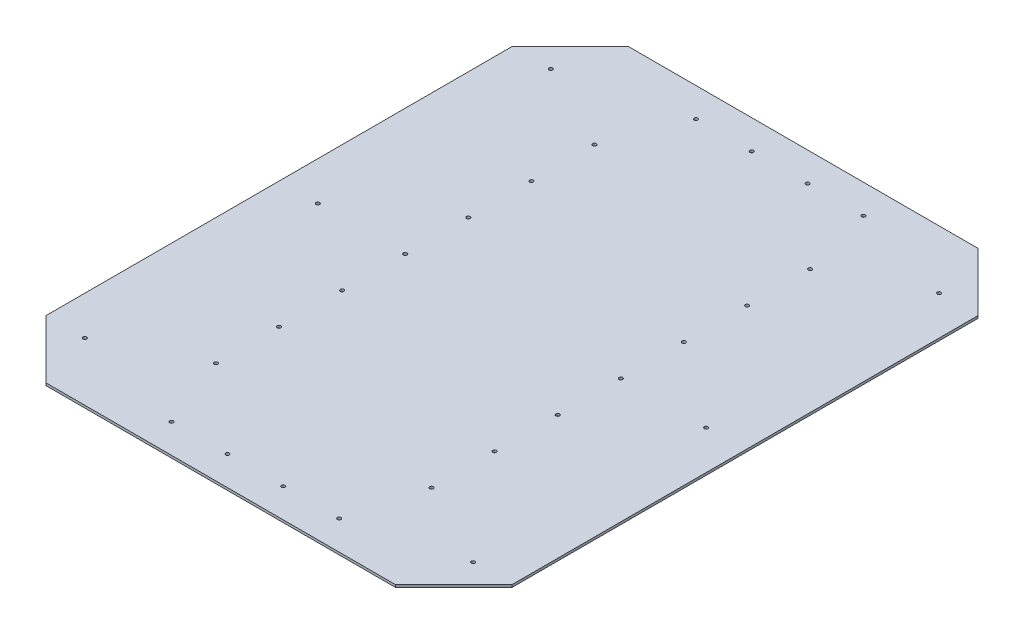
from build123d import *

# Parameters (mm, degrees)
SKETCH1_W               = 1219.2
SKETCH1_H               = 1524
BOSS_EXTRUDE1_DEPTH     = 6.35
SKETCH20_R              = 1360.3436129
SKETCH20_R_2            = 1357.8036129
CUT_EXTRUDE_THIN2_DEPTH = 6.35
SKETCH24_R              = 4.7625
CUT_EXTRUDE13_DEPTH     = 976.856794053


with BuildPart() as part:
    # Sketch1 → Boss-Extrude1 (new body)
    with BuildSketch(Plane(origin=(0, 0, 0), x_dir=(1, 0, 0), z_dir=(0, 1, 0))):
        Rectangle(SKETCH1_W, SKETCH1_H)
    extrude(amount=BOSS_EXTRUDE1_DEPTH)

    # Sketch20 → Cut-Extrude-Thin2 (cut)
    with BuildSketch(Plane(origin=(0, 6.35, 0), x_dir=(1, 0, 0), z_dir=(0, 1, 0))):
        Circle(SKETCH20_R)
        Circle(SKETCH20_R_2, mode=Mode.SUBTRACT)
        Polygon((612.14, -610.652102448), (458.252102448, -764.54), (0, -764.54), (-458.252102448, -764.54), (-612.14, -610.652102448), (-612.14, 610.652102448), (-458.252102448, 764.54), (0, 764.54), (458.252102448, 764.54), (612.14, 610.652102448), align=None)
        Polygon((609.6, -609.6), (457.2, -762), (0, -762), (-457.2, -762), (-609.6, -609.6), (-609.6, 609.6), (-457.2, 762), (0, 762), (457.2, 762), (609.6, 609.6), align=None, mode=Mode.SUBTRACT)
    extrude(amount=-CUT_EXTRUDE_THIN2_DEPTH, mode=Mode.SUBTRACT)


with BuildPart() as cut_extrude_thin2_kept_piece:
    # of the separate pieces the step leaves, the one the design keeps (cut_extrude_thin2_pieces_kept)
    add(part.part.solids().sort_by_distance((457.2, 6.35, -762))[0])

    # Sketch24 → Cut-Extrude13 (cut, through all)
    with BuildSketch(Plane.XZ):
        with Locations(Location((-279.400040578, -0.001758284, 0), (0, 0, 270))):
            Circle(SKETCH24_R)
        with Locations(Location((-279.400040578, 165.098241716, 0), (0, 0, 270))):
            Circle(SKETCH24_R)
        with Locations(Location((-279.400040578, 330.198241716, 0), (0, 0, 270))):
            Circle(SKETCH24_R)
        with Locations(Location((-279.400040578, 495.298241716, 0), (0, 0, 270))):
            Circle(SKETCH24_R)
        with Locations(Location((87.436757408, 685.8, 0), (0, 0, 270))):
            Circle(SKETCH24_R)
        with Locations(Location((233.486757408, 685.8, 0), (0, 0, 270))):
            Circle(SKETCH24_R)
        with Locations(Location((284.709719006, 495.298241716, 0), (0, 0, 270))):
            Circle(SKETCH24_R)
        with Locations(Location((284.709719006, 330.198241716, 0), (0, 0, 270))):
            Circle(SKETCH24_R)
        with Locations(Location((284.709719006, 165.098241716, 0), (0, 0, 270))):
            Circle(SKETCH24_R)
        with Locations(Location((284.709719006, -0.001758284, 0), (0, 0, 270))):
            Circle(SKETCH24_R)
        with Locations(Location((284.709719006, -165.101758284, 0), (0, 0, 270))):
            Circle(SKETCH24_R)
        with Locations(Location((284.709719006, -330.201758284, 0), (0, 0, 270))):
            Circle(SKETCH24_R)
        with Locations(Location((284.709719006, -495.301758284, 0), (0, 0, 270))):
            Circle(SKETCH24_R)
        with Locations(Location((233.486757408, -685.8, 0), (0, 0, 270))):
            Circle(SKETCH24_R)
        with Locations(Location((87.436757408, -685.8, 0), (0, 0, 270))):
            Circle(SKETCH24_R)
        with Locations(Location((-58.613242592, -685.8, 0), (0, 0, 270))):
            Circle(SKETCH24_R)
        with Locations(Location((-204.663242592, -685.8, 0), (0, 0, 270))):
            Circle(SKETCH24_R)
        with Locations(Location((-279.400040578, -495.301758284, 0), (0, 0, 270))):
            Circle(SKETCH24_R)
        with Locations(Location((-279.400040578, -330.201758284, 0), (0, 0, 270))):
            Circle(SKETCH24_R)
        with Locations(Location((-279.400040578, -165.101758284, 0), (0, 0, 270))):
            Circle(SKETCH24_R)
        with Locations(Location((508, -609.6, 0), (0, 0, 270))):
            Circle(SKETCH24_R)
        with Locations(Location((508, 609.6, 0), (0, 0, 270))):
            Circle(SKETCH24_R)
        with Locations(Location((-508, -609.6, 0), (0, 0, 270))):
            Circle(SKETCH24_R)
        with Locations(Location((-508, 609.6, 0), (0, 0, 270))):
            Circle(SKETCH24_R)
        with Locations(Location((-204.663242592, 685.8, 0), (0, 0, 270))):
            Circle(SKETCH24_R)
        with Locations(Location((-58.613242592, 685.8, 0), (0, 0, 270))):
            Circle(SKETCH24_R)
        with Locations(Location((-508, 0, 0), (0, 0, 270))):
            Circle(SKETCH24_R)
        with Locations(Location((508, 0, 0), (0, 0, 270))):
            Circle(SKETCH24_R)
    extrude(amount=-CUT_EXTRUDE13_DEPTH, mode=Mode.SUBTRACT)


solid = cut_extrude_thin2_kept_piece.part
